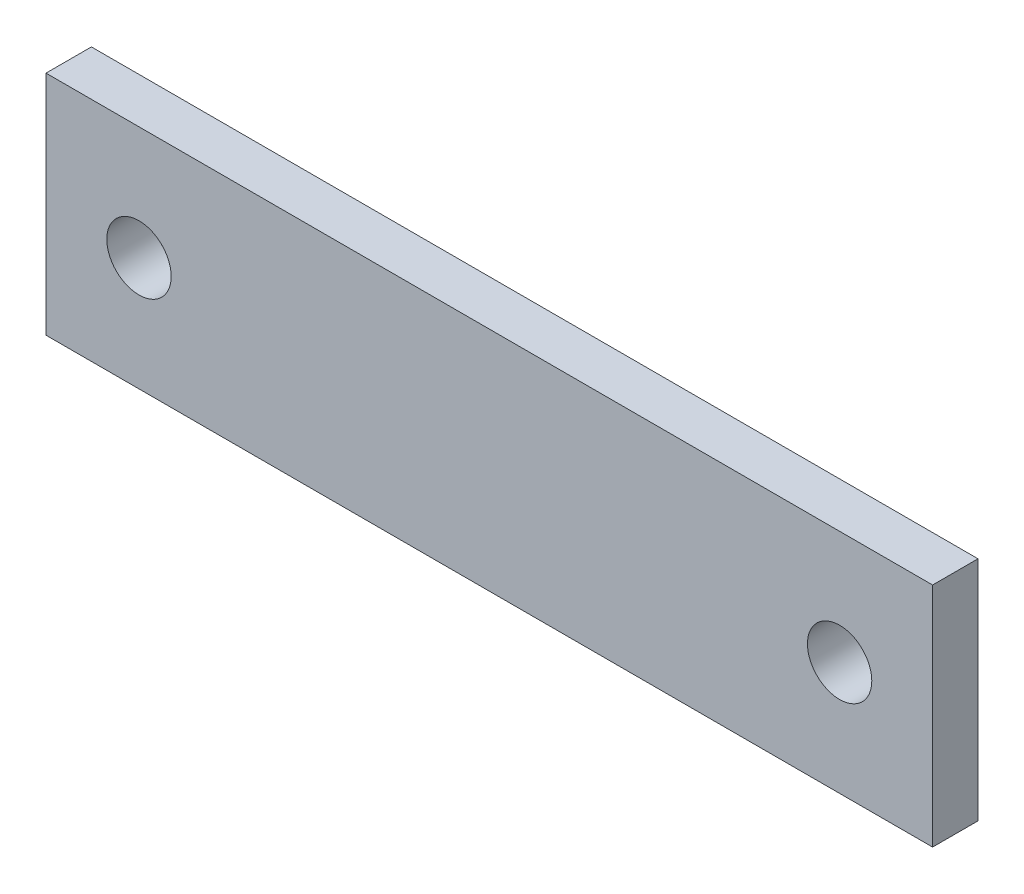
from build123d import *

# Parameters (mm, degrees)
SKETCH2_W            = 62.0014
SKETCH2_H            = 15.875
BOSS_EXTRUDE1_DEPTH  = 3.175
M4_CLEARANCE_HOLE1_D = 4.5


with BuildPart() as part:
    # Sketch2 → Boss-Extrude1 (new body)
    with BuildSketch(Plane.XY):
        with Locations((0.422222459, 8.999286052)):
            Rectangle(SKETCH2_W, SKETCH2_H)
    extrude(amount=BOSS_EXTRUDE1_DEPTH)

    # M4 Clearance Hole1 (through all)
    with Locations(Plane.XY.offset(3.175)):
        with Locations((-24.076077541, 8.999286052), (24.920522459, 8.999286052)):
            Hole(M4_CLEARANCE_HOLE1_D / 2)


solid = part.part
